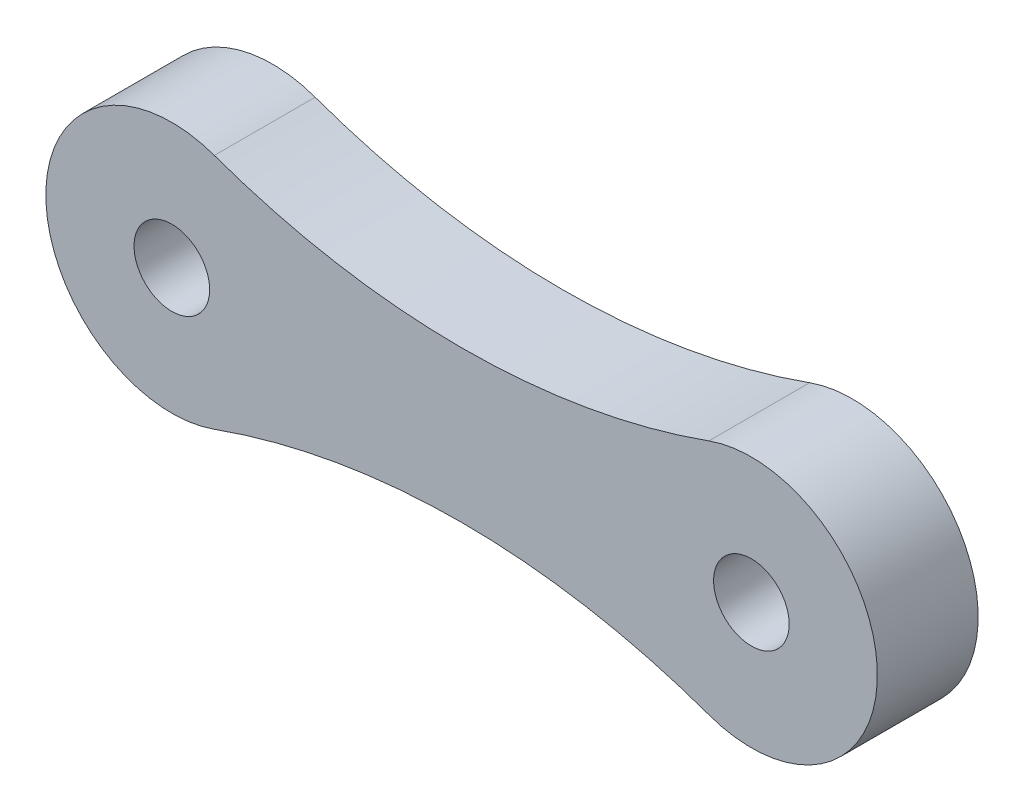
from build123d import *

# Parameters (mm, degrees)
SKETCH1_R           = 2.5
SKETCH1_R_2         = 0.75
BOSS_EXTRUDE1_DEPTH = 2


with BuildPart() as part:
    # Sketch1 → Boss-Extrude1 (new body)
    with BuildSketch(Plane.XY):
        with Locations((-5.75, 0)):
            Circle(SKETCH1_R)
        with Locations((-5.75, 0)):
            Circle(SKETCH1_R_2, mode=Mode.SUBTRACT)
        with BuildLine():
            ThreePointArc((-4.905963303, 2.353211009), (-3.705483952, 1.438733515), (-3.25, 0))
            ThreePointArc((-3.25, 0), (-3.705483952, -1.438733515), (-4.905963303, -2.353211009))
            ThreePointArc((-4.905963303, -2.353211009), (0, -1.5), (4.905963303, -2.353211009))
            ThreePointArc((4.905963303, -2.353211009), (3.25, 0), (4.905963303, 2.353211009))
            ThreePointArc((4.905963303, 2.353211009), (0, 1.5), (-4.905963303, 2.353211009))
        make_face()
        with Locations((5.75, 0)):
            Circle(SKETCH1_R)
        with Locations((5.75, 0)):
            Circle(SKETCH1_R_2, mode=Mode.SUBTRACT)
    extrude(amount=BOSS_EXTRUDE1_DEPTH)


solid = part.part
